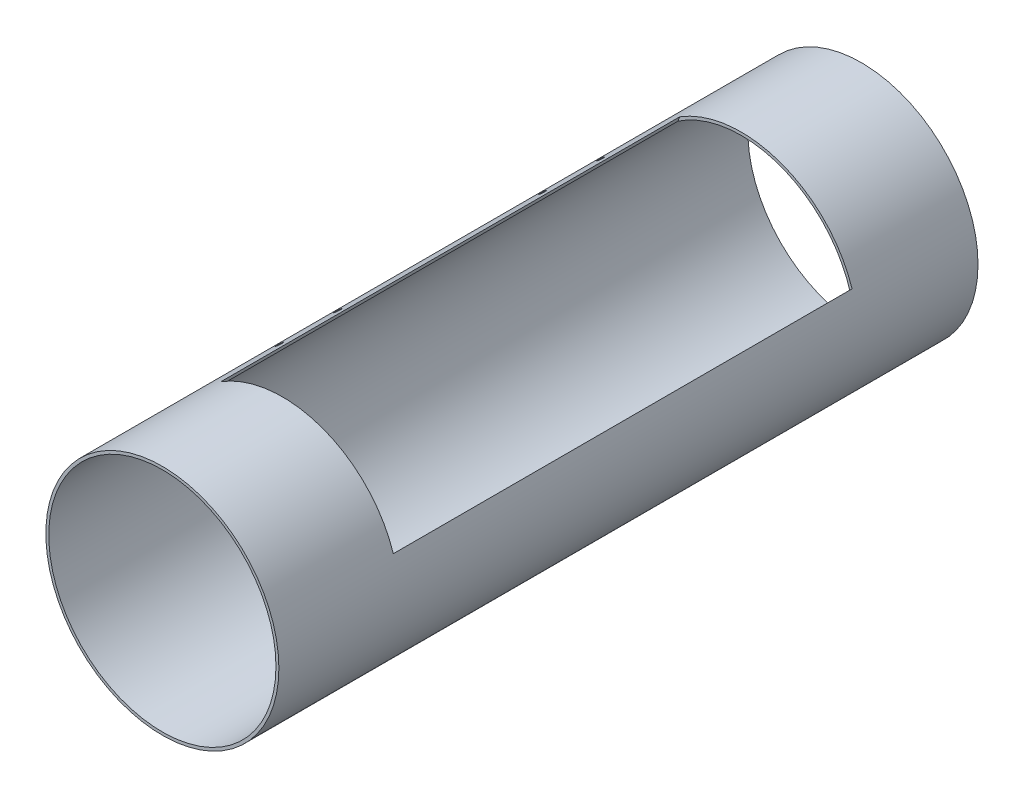
from build123d import *

# Parameters (mm, degrees)
SKETCH2_R           = 50.8
SKETCH2_R_2         = 49.53
BOSS_EXTRUDE1_DEPTH = 304.8
CUT_EXTRUDE1_REACH  = 67.111
SKETCH3_W           = 80
SKETCH3_H           = 200
SKETCH7_R           = 1.5
CUT_EXTRUDE2_DEPTH  = 10


with BuildPart() as part:
    # Sketch2 → Boss-Extrude1 (new body)
    with BuildSketch(Plane.XY):
        Circle(SKETCH2_R)
        Circle(SKETCH2_R_2, mode=Mode.SUBTRACT)
    extrude(amount=BOSS_EXTRUDE1_DEPTH)

    # Sketch3 → Cut-Extrude1 (cut, up to next)
    with BuildSketch(Plane(origin=(0, 0, 0), x_dir=(0.939692621, -0.342020143, 0), z_dir=(0.342020143, 0.939692621, 0)), mode=Mode.PRIVATE) as cut_extrude1_sk1:
        with Locations((0, -152.4)):
            Rectangle(SKETCH3_W, SKETCH3_H)
    cut_extrude1_tool1 = extrude(cut_extrude1_sk1.sketch, amount=CUT_EXTRUDE1_REACH, mode=Mode.PRIVATE) & part.part
    add(cut_extrude1_tool1.solids().sort_by_distance((0, 0, 152.4))[0], mode=Mode.SUBTRACT)

    # Sketch7 → Cut-Extrude2 (cut)
    with BuildSketch(Plane(origin=(-78.038389788, 6.264218534, 0), x_dir=(-0.785593968, -0.618742367, 0), z_dir=(0.618742367, -0.785593968, 0))):
        with Locations((-57.430550893, -222.4)):
            Circle(SKETCH7_R)
        with Locations((-57.430550893, -197)):
            Circle(SKETCH7_R)
        with Locations((-57.430550893, -107.8)):
            Circle(SKETCH7_R)
        with Locations((-57.430550893, -82.4)):
            Circle(SKETCH7_R)
    extrude(amount=CUT_EXTRUDE2_DEPTH, mode=Mode.SUBTRACT)


solid = part.part
